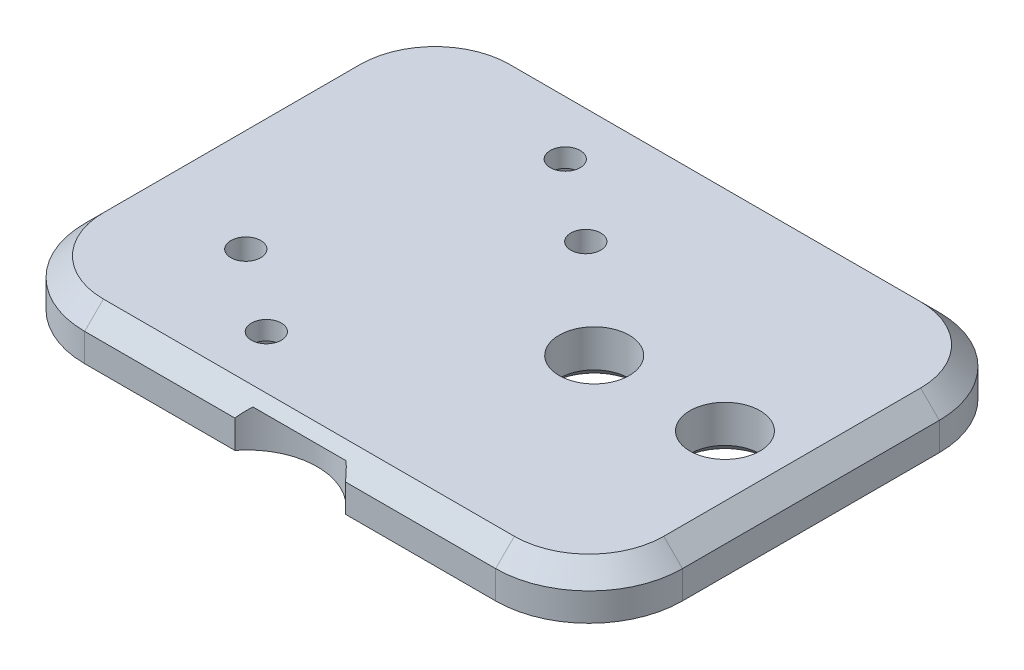
from build123d import *

# Parameters (mm, degrees)
SKETCH1_W           = 64
SKETCH1_H           = 47.5
SKETCH1_R           = 1.6
SKETCH1_R_2         = 3.75
BOSS_EXTRUDE1_DEPTH = 5
SKETCH2_R           = 1.6
CUT_EXTRUDE1_DEPTH  = 6
CUT_EXTRUDE2_DEPTH  = 3
FILLET1_R           = 10
FILLET2_R           = 10
CHAMFER1_SIZE       = 2
CHAMFER2_SIZE       = 1
SKETCH4_R           = 5.25
SKETCH4_R_2         = 7.5
CUT_EXTRUDE3_DEPTH  = 4


with BuildPart() as part:
    # Sketch1 → Boss-Extrude1 (new body)
    with BuildSketch(Plane(origin=(0, 0, 0), x_dir=(1, 0, 0), z_dir=(0, 1, 0))):
        with Locations((-37.591918828, -42.97941453)):
            Rectangle(SKETCH1_W, SKETCH1_H)
        with Locations((-39.091918828, -33.57941453)):
            Circle(SKETCH1_R, mode=Mode.SUBTRACT)
        with Locations((-56.591918828, -52.47941453)):
            Circle(SKETCH1_R, mode=Mode.SUBTRACT)
        with Locations((-28.091918828, -43.67941453)):
            Circle(SKETCH1_R_2, mode=Mode.SUBTRACT)
        with Locations((-14.091918828, -43.67941453)):
            Circle(SKETCH1_R_2, mode=Mode.SUBTRACT)
    extrude(amount=BOSS_EXTRUDE1_DEPTH)

    # Sketch2 → Cut-Extrude1 (cut, through all)
    with BuildSketch(Plane.XZ):
        with Locations((-47.841918828, 59.02941453)):
            Circle(SKETCH2_R)
        with Locations((-47.841918828, 27.02941453)):
            Circle(SKETCH2_R)
    extrude(amount=-CUT_EXTRUDE1_DEPTH, mode=Mode.SUBTRACT)

    # Sketch3 → Cut-Extrude2 (cut)
    with BuildSketch(Plane(origin=(0, 0, 0), x_dir=(-1, 0, 0), z_dir=(0, -1, 0))):
        Polygon((49.429632069, -56.27941453), (46.254205588, -56.27941453), (44.666492348, -59.02941453), (46.254205588, -61.77941453), (49.429632069, -61.77941453), (51.017345309, -59.02941453), align=None)
        Polygon((46.254205588, -29.77941453), (49.429632069, -29.77941453), (51.017345309, -27.02941453), (49.429632069, -24.27941453), (46.254205588, -24.27941453), (44.666492348, -27.02941453), align=None)
    extrude(amount=-CUT_EXTRUDE2_DEPTH, mode=Mode.SUBTRACT)

    # Fillet1
    fillet1_edges = [part.edges().sort_by_distance(p)[0] for p in [
        (-69.591918828, 2.5, 19.22941453),
        (-5.591918828, 2.5, 19.22941453),
    ]]
    fillet(fillet1_edges, radius=FILLET1_R)

    # Fillet2
    fillet2_edges = [part.edges().sort_by_distance(p)[0] for p in [
        (-5.591918828, 2.5, 66.72941453),
        (-69.591918828, 2.5, 66.72941453),
    ]]
    fillet(fillet2_edges, radius=FILLET2_R)

    # Chamfer1
    chamfer1_edges = [part.edges().sort_by_distance(p)[0] for p in [
        (-37.591918828, 5, 19.22941453),
        (-69.591918828, 5, 42.97941453),
        (-66.66298664, 5, 22.158346718),
        (-8.520851016, 5, 22.158346718),
        (-5.591918828, 5, 42.97941453),
        (-37.591918828, 5, 66.72941453),
        (-66.66298664, 5, 63.800482342),
        (-8.520851016, 5, 63.800482342),
    ]]
    chamfer(chamfer1_edges, length=CHAMFER1_SIZE)

    # Chamfer2
    chamfer2_edges = [part.edges().sort_by_distance(p)[0] for p in [
        (-17.841918828, 0, 43.67941453),
        (-31.841918828, 0, 43.67941453),
    ]]
    chamfer(chamfer2_edges, length=CHAMFER2_SIZE)

    # Sketch4 → Cut-Extrude3 (cut)
    with BuildSketch(Plane(origin=(0, 0, 0), x_dir=(1, 0, 0), z_dir=(0, 1, 0))):
        with Locations((-57.591918828, -31.12941453)):
            Circle(SKETCH4_R)
        with Locations((-17.591918828, -31.12941453)):
            Circle(SKETCH4_R)
        with Locations((-37.591918828, -71.32941453)):
            Circle(SKETCH4_R_2)
    extrude(amount=CUT_EXTRUDE3_DEPTH, mode=Mode.SUBTRACT)


solid = part.part
